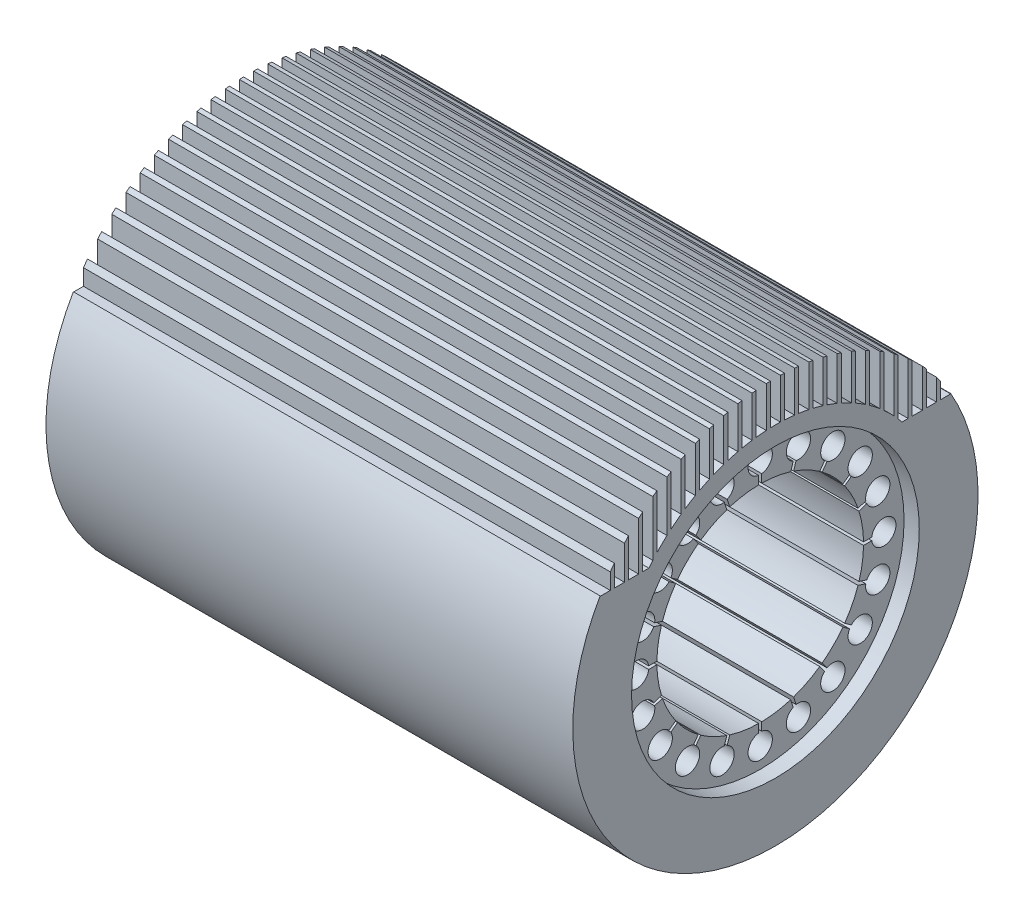
from build123d import *

# Parameters (mm, degrees)
CUT_EXTRUDE1_REACH = 262
CUT_EXTRUDE3_DEPTH = 260


with BuildPart() as part:
    # Sketch1 → Revolve1 (revolve)
    with BuildSketch(Plane.XY):
        Polygon((-130, 100), (130, 100), (130, 71), (122.5, 71), (122.5, 51), (-122.5, 51), (-122.5, 71), (-130, 71), align=None)
    revolve(axis=Axis((-130, 0, 0), (1, 0, 0)))

    # Sketch2 → Cut-Extrude1 (cut, up to next)
    with BuildSketch(Plane.ZY.offset(130), mode=Mode.PRIVATE) as cut_extrude1_sk1:
        with BuildLine():
            Line((-0.75, 55.04705955), (-0.75, 50.994484996))
            ThreePointArc((-0.75, 50.994484996), (0, 51), (0.75, 50.994484996))
            Line((0.75, 50.994484996), (0.75, 55.04705955))
            ThreePointArc((0.75, 55.04705955), (0, 67), (-0.75, 55.04705955))
        make_face()
    cut_extrude1_tool1 = extrude(cut_extrude1_sk1.sketch, amount=-CUT_EXTRUDE1_REACH, mode=Mode.PRIVATE) & part.part
    add(cut_extrude1_tool1.solids().sort_by_distance((-130, 60.595645, 0))[0], mode=Mode.SUBTRACT)
    # Sketch2 → Cut-Extrude1 (cut, up to next)
    with BuildSketch(Plane.ZY.offset(130), mode=Mode.PRIVATE) as cut_extrude1_sk2:
        with BuildLine():
            Line((16.297184504, 52.584627434), (15.044870096, 48.730399996))
            ThreePointArc((15.044870096, 48.730399996), (15.759866713, 48.503882331), (16.47145487, 48.266874505))
            Line((16.47145487, 48.266874505), (17.723769279, 52.121101942))
            ThreePointArc((17.723769279, 52.121101942), (20.704138623, 63.720786592), (16.297184504, 52.584627434))
        make_face()
    cut_extrude1_tool2 = extrude(cut_extrude1_sk2.sketch, amount=-CUT_EXTRUDE1_REACH, mode=Mode.PRIVATE) & part.part
    add(cut_extrude1_tool2.solids().sort_by_distance((-130, 57.629883, 18.725084))[0], mode=Mode.SUBTRACT)
    # Sketch2 → Cut-Extrude1 (cut, up to next)
    with BuildSketch(Plane.ZY.offset(130), mode=Mode.PRIVATE) as cut_extrude1_sk3:
        with BuildLine():
            Line((31.74908704, 44.974845606), (29.367043483, 41.69624392))
            ThreePointArc((29.367043483, 41.69624392), (29.977047867, 41.259866713), (30.580568975, 40.814566042))
            Line((30.580568975, 40.814566042), (32.962612531, 44.093167727))
            ThreePointArc((32.962612531, 44.093167727), (39.381611904, 54.204138623), (31.74908704, 44.974845606))
        make_face()
    cut_extrude1_tool3 = extrude(cut_extrude1_sk3.sketch, amount=-CUT_EXTRUDE1_REACH, mode=Mode.PRIVATE) & part.part
    add(cut_extrude1_tool3.solids().sort_by_distance((-130, 49.022907, 35.617227))[0], mode=Mode.SUBTRACT)
    # Sketch2 → Cut-Extrude1 (cut, up to next)
    with BuildSketch(Plane.ZY.offset(130), mode=Mode.PRIVATE) as cut_extrude1_sk4:
        with BuildLine():
            Line((44.093167727, 32.962612531), (40.814566042, 30.580568975))
            ThreePointArc((40.814566042, 30.580568975), (41.259866713, 29.977047867), (41.69624392, 29.367043483))
            Line((41.69624392, 29.367043483), (44.974845606, 31.74908704))
            ThreePointArc((44.974845606, 31.74908704), (54.204138623, 39.381611904), (44.093167727, 32.962612531))
        make_face()
    cut_extrude1_tool4 = extrude(cut_extrude1_sk4.sketch, amount=-CUT_EXTRUDE1_REACH, mode=Mode.PRIVATE) & part.part
    add(cut_extrude1_tool4.solids().sort_by_distance((-130, 35.617227, 49.022907))[0], mode=Mode.SUBTRACT)
    # Sketch2 → Cut-Extrude1 (cut, up to next)
    with BuildSketch(Plane.ZY.offset(130), mode=Mode.PRIVATE) as cut_extrude1_sk5:
        with BuildLine():
            Line((52.121101942, 17.723769279), (48.266874505, 16.47145487))
            ThreePointArc((48.266874505, 16.47145487), (48.503882331, 15.759866713), (48.730399996, 15.044870096))
            Line((48.730399996, 15.044870096), (52.584627434, 16.297184504))
            ThreePointArc((52.584627434, 16.297184504), (63.720786592, 20.704138623), (52.121101942, 17.723769279))
        make_face()
    cut_extrude1_tool5 = extrude(cut_extrude1_sk5.sketch, amount=-CUT_EXTRUDE1_REACH, mode=Mode.PRIVATE) & part.part
    add(cut_extrude1_tool5.solids().sort_by_distance((-130, 18.725084, 57.629883))[0], mode=Mode.SUBTRACT)
    # Sketch2 → Cut-Extrude1 (cut, up to next)
    with BuildSketch(Plane.ZY.offset(130), mode=Mode.PRIVATE) as cut_extrude1_sk6:
        with BuildLine():
            Line((55.04705955, 0.75), (50.994484996, 0.75))
            ThreePointArc((50.994484996, 0.75), (51, 0), (50.994484996, -0.75))
            Line((50.994484996, -0.75), (55.04705955, -0.75))
            ThreePointArc((55.04705955, -0.75), (67, 0), (55.04705955, 0.75))
        make_face()
    cut_extrude1_tool6 = extrude(cut_extrude1_sk6.sketch, amount=-CUT_EXTRUDE1_REACH, mode=Mode.PRIVATE) & part.part
    add(cut_extrude1_tool6.solids().sort_by_distance((-130, 0, 60.595645))[0], mode=Mode.SUBTRACT)
    # Sketch2 → Cut-Extrude1 (cut, up to next)
    with BuildSketch(Plane.ZY.offset(130), mode=Mode.PRIVATE) as cut_extrude1_sk7:
        with BuildLine():
            Line((52.584627434, -16.297184504), (48.730399996, -15.044870096))
            ThreePointArc((48.730399996, -15.044870096), (48.503882331, -15.759866713), (48.266874505, -16.47145487))
            Line((48.266874505, -16.47145487), (52.121101942, -17.723769279))
            ThreePointArc((52.121101942, -17.723769279), (63.720786592, -20.704138623), (52.584627434, -16.297184504))
        make_face()
    cut_extrude1_tool7 = extrude(cut_extrude1_sk7.sketch, amount=-CUT_EXTRUDE1_REACH, mode=Mode.PRIVATE) & part.part
    add(cut_extrude1_tool7.solids().sort_by_distance((-130, -18.725084, 57.629883))[0], mode=Mode.SUBTRACT)
    # Sketch2 → Cut-Extrude1 (cut, up to next)
    with BuildSketch(Plane.ZY.offset(130), mode=Mode.PRIVATE) as cut_extrude1_sk8:
        with BuildLine():
            Line((44.974845606, -31.74908704), (41.69624392, -29.367043483))
            ThreePointArc((41.69624392, -29.367043483), (41.259866713, -29.977047867), (40.814566042, -30.580568975))
            Line((40.814566042, -30.580568975), (44.093167727, -32.962612531))
            ThreePointArc((44.093167727, -32.962612531), (54.204138623, -39.381611904), (44.974845606, -31.74908704))
        make_face()
    cut_extrude1_tool8 = extrude(cut_extrude1_sk8.sketch, amount=-CUT_EXTRUDE1_REACH, mode=Mode.PRIVATE) & part.part
    add(cut_extrude1_tool8.solids().sort_by_distance((-130, -35.617227, 49.022907))[0], mode=Mode.SUBTRACT)
    # Sketch2 → Cut-Extrude1 (cut, up to next)
    with BuildSketch(Plane.ZY.offset(130), mode=Mode.PRIVATE) as cut_extrude1_sk9:
        with BuildLine():
            Line((32.962612531, -44.093167727), (30.580568975, -40.814566042))
            ThreePointArc((30.580568975, -40.814566042), (29.977047867, -41.259866713), (29.367043483, -41.69624392))
            Line((29.367043483, -41.69624392), (31.74908704, -44.974845606))
            ThreePointArc((31.74908704, -44.974845606), (39.381611904, -54.204138623), (32.962612531, -44.093167727))
        make_face()
    cut_extrude1_tool9 = extrude(cut_extrude1_sk9.sketch, amount=-CUT_EXTRUDE1_REACH, mode=Mode.PRIVATE) & part.part
    add(cut_extrude1_tool9.solids().sort_by_distance((-130, -49.022907, 35.617227))[0], mode=Mode.SUBTRACT)
    # Sketch2 → Cut-Extrude1 (cut, up to next)
    with BuildSketch(Plane.ZY.offset(130), mode=Mode.PRIVATE) as cut_extrude1_sk10:
        with BuildLine():
            Line((17.723769279, -52.121101942), (16.47145487, -48.266874505))
            ThreePointArc((16.47145487, -48.266874505), (15.759866713, -48.503882331), (15.044870096, -48.730399996))
            Line((15.044870096, -48.730399996), (16.297184504, -52.584627434))
            ThreePointArc((16.297184504, -52.584627434), (20.704138623, -63.720786592), (17.723769279, -52.121101942))
        make_face()
    cut_extrude1_tool10 = extrude(cut_extrude1_sk10.sketch, amount=-CUT_EXTRUDE1_REACH, mode=Mode.PRIVATE) & part.part
    add(cut_extrude1_tool10.solids().sort_by_distance((-130, -57.629883, 18.725084))[0], mode=Mode.SUBTRACT)
    # Sketch2 → Cut-Extrude1 (cut, up to next)
    with BuildSketch(Plane.ZY.offset(130), mode=Mode.PRIVATE) as cut_extrude1_sk11:
        with BuildLine():
            Line((0.75, -55.04705955), (0.75, -50.994484996))
            ThreePointArc((0.75, -50.994484996), (0, -51), (-0.75, -50.994484996))
            Line((-0.75, -50.994484996), (-0.75, -55.04705955))
            ThreePointArc((-0.75, -55.04705955), (0, -67), (0.75, -55.04705955))
        make_face()
    cut_extrude1_tool11 = extrude(cut_extrude1_sk11.sketch, amount=-CUT_EXTRUDE1_REACH, mode=Mode.PRIVATE) & part.part
    add(cut_extrude1_tool11.solids().sort_by_distance((-130, -60.595645, 0))[0], mode=Mode.SUBTRACT)
    # Sketch2 → Cut-Extrude1 (cut, up to next)
    with BuildSketch(Plane.ZY.offset(130), mode=Mode.PRIVATE) as cut_extrude1_sk12:
        with BuildLine():
            Line((-16.297184504, -52.584627434), (-15.044870096, -48.730399996))
            ThreePointArc((-15.044870096, -48.730399996), (-15.759866713, -48.503882331), (-16.47145487, -48.266874505))
            Line((-16.47145487, -48.266874505), (-17.723769279, -52.121101942))
            ThreePointArc((-17.723769279, -52.121101942), (-20.704138623, -63.720786592), (-16.297184504, -52.584627434))
        make_face()
    cut_extrude1_tool12 = extrude(cut_extrude1_sk12.sketch, amount=-CUT_EXTRUDE1_REACH, mode=Mode.PRIVATE) & part.part
    add(cut_extrude1_tool12.solids().sort_by_distance((-130, -57.629883, -18.725084))[0], mode=Mode.SUBTRACT)
    # Sketch2 → Cut-Extrude1 (cut, up to next)
    with BuildSketch(Plane.ZY.offset(130), mode=Mode.PRIVATE) as cut_extrude1_sk13:
        with BuildLine():
            Line((-31.74908704, -44.974845606), (-29.367043483, -41.69624392))
            ThreePointArc((-29.367043483, -41.69624392), (-29.977047867, -41.259866713), (-30.580568975, -40.814566042))
            Line((-30.580568975, -40.814566042), (-32.962612531, -44.093167727))
            ThreePointArc((-32.962612531, -44.093167727), (-39.381611904, -54.204138623), (-31.74908704, -44.974845606))
        make_face()
    cut_extrude1_tool13 = extrude(cut_extrude1_sk13.sketch, amount=-CUT_EXTRUDE1_REACH, mode=Mode.PRIVATE) & part.part
    add(cut_extrude1_tool13.solids().sort_by_distance((-130, -49.022907, -35.617227))[0], mode=Mode.SUBTRACT)
    # Sketch2 → Cut-Extrude1 (cut, up to next)
    with BuildSketch(Plane.ZY.offset(130), mode=Mode.PRIVATE) as cut_extrude1_sk14:
        with BuildLine():
            Line((-44.093167727, -32.962612531), (-40.814566042, -30.580568975))
            ThreePointArc((-40.814566042, -30.580568975), (-41.259866713, -29.977047867), (-41.69624392, -29.367043483))
            Line((-41.69624392, -29.367043483), (-44.974845606, -31.74908704))
            ThreePointArc((-44.974845606, -31.74908704), (-54.204138623, -39.381611904), (-44.093167727, -32.962612531))
        make_face()
    cut_extrude1_tool14 = extrude(cut_extrude1_sk14.sketch, amount=-CUT_EXTRUDE1_REACH, mode=Mode.PRIVATE) & part.part
    add(cut_extrude1_tool14.solids().sort_by_distance((-130, -35.617227, -49.022907))[0], mode=Mode.SUBTRACT)
    # Sketch2 → Cut-Extrude1 (cut, up to next)
    with BuildSketch(Plane.ZY.offset(130), mode=Mode.PRIVATE) as cut_extrude1_sk15:
        with BuildLine():
            Line((-52.121101942, -17.723769279), (-48.266874505, -16.47145487))
            ThreePointArc((-48.266874505, -16.47145487), (-48.503882331, -15.759866713), (-48.730399996, -15.044870096))
            Line((-48.730399996, -15.044870096), (-52.584627434, -16.297184504))
            ThreePointArc((-52.584627434, -16.297184504), (-63.720786592, -20.704138623), (-52.121101942, -17.723769279))
        make_face()
    cut_extrude1_tool15 = extrude(cut_extrude1_sk15.sketch, amount=-CUT_EXTRUDE1_REACH, mode=Mode.PRIVATE) & part.part
    add(cut_extrude1_tool15.solids().sort_by_distance((-130, -18.725084, -57.629883))[0], mode=Mode.SUBTRACT)
    # Sketch2 → Cut-Extrude1 (cut, up to next)
    with BuildSketch(Plane.ZY.offset(130), mode=Mode.PRIVATE) as cut_extrude1_sk16:
        with BuildLine():
            Line((-55.04705955, -0.75), (-50.994484996, -0.75))
            ThreePointArc((-50.994484996, -0.75), (-51, 0), (-50.994484996, 0.75))
            Line((-50.994484996, 0.75), (-55.04705955, 0.75))
            ThreePointArc((-55.04705955, 0.75), (-67, 0), (-55.04705955, -0.75))
        make_face()
    cut_extrude1_tool16 = extrude(cut_extrude1_sk16.sketch, amount=-CUT_EXTRUDE1_REACH, mode=Mode.PRIVATE) & part.part
    add(cut_extrude1_tool16.solids().sort_by_distance((-130, 0, -60.595645))[0], mode=Mode.SUBTRACT)
    # Sketch2 → Cut-Extrude1 (cut, up to next)
    with BuildSketch(Plane.ZY.offset(130), mode=Mode.PRIVATE) as cut_extrude1_sk17:
        with BuildLine():
            Line((-52.584627434, 16.297184504), (-48.730399996, 15.044870096))
            ThreePointArc((-48.730399996, 15.044870096), (-48.503882331, 15.759866713), (-48.266874505, 16.47145487))
            Line((-48.266874505, 16.47145487), (-52.121101942, 17.723769279))
            ThreePointArc((-52.121101942, 17.723769279), (-63.720786592, 20.704138623), (-52.584627434, 16.297184504))
        make_face()
    cut_extrude1_tool17 = extrude(cut_extrude1_sk17.sketch, amount=-CUT_EXTRUDE1_REACH, mode=Mode.PRIVATE) & part.part
    add(cut_extrude1_tool17.solids().sort_by_distance((-130, 18.725084, -57.629883))[0], mode=Mode.SUBTRACT)
    # Sketch2 → Cut-Extrude1 (cut, up to next)
    with BuildSketch(Plane.ZY.offset(130), mode=Mode.PRIVATE) as cut_extrude1_sk18:
        with BuildLine():
            Line((-44.974845606, 31.74908704), (-41.69624392, 29.367043483))
            ThreePointArc((-41.69624392, 29.367043483), (-41.259866713, 29.977047867), (-40.814566042, 30.580568975))
            Line((-40.814566042, 30.580568975), (-44.093167727, 32.962612531))
            ThreePointArc((-44.093167727, 32.962612531), (-54.204138623, 39.381611904), (-44.974845606, 31.74908704))
        make_face()
    cut_extrude1_tool18 = extrude(cut_extrude1_sk18.sketch, amount=-CUT_EXTRUDE1_REACH, mode=Mode.PRIVATE) & part.part
    add(cut_extrude1_tool18.solids().sort_by_distance((-130, 35.617227, -49.022907))[0], mode=Mode.SUBTRACT)
    # Sketch2 → Cut-Extrude1 (cut, up to next)
    with BuildSketch(Plane.ZY.offset(130), mode=Mode.PRIVATE) as cut_extrude1_sk19:
        with BuildLine():
            Line((-32.962612531, 44.093167727), (-30.580568975, 40.814566042))
            ThreePointArc((-30.580568975, 40.814566042), (-29.977047867, 41.259866713), (-29.367043483, 41.69624392))
            Line((-29.367043483, 41.69624392), (-31.74908704, 44.974845606))
            ThreePointArc((-31.74908704, 44.974845606), (-39.381611904, 54.204138623), (-32.962612531, 44.093167727))
        make_face()
    cut_extrude1_tool19 = extrude(cut_extrude1_sk19.sketch, amount=-CUT_EXTRUDE1_REACH, mode=Mode.PRIVATE) & part.part
    add(cut_extrude1_tool19.solids().sort_by_distance((-130, 49.022907, -35.617227))[0], mode=Mode.SUBTRACT)
    # Sketch2 → Cut-Extrude1 (cut, up to next)
    with BuildSketch(Plane.ZY.offset(130), mode=Mode.PRIVATE) as cut_extrude1_sk20:
        with BuildLine():
            Line((-17.723769279, 52.121101942), (-16.47145487, 48.266874505))
            ThreePointArc((-16.47145487, 48.266874505), (-15.759866713, 48.503882331), (-15.044870096, 48.730399996))
            Line((-15.044870096, 48.730399996), (-16.297184504, 52.584627434))
            ThreePointArc((-16.297184504, 52.584627434), (-20.704138623, 63.720786592), (-17.723769279, 52.121101942))
        make_face()
    cut_extrude1_tool20 = extrude(cut_extrude1_sk20.sketch, amount=-CUT_EXTRUDE1_REACH, mode=Mode.PRIVATE) & part.part
    add(cut_extrude1_tool20.solids().sort_by_distance((-130, 57.629883, -18.725084))[0], mode=Mode.SUBTRACT)

    # Sketch4 → Cut-Extrude3 (cut)
    with BuildSketch(Plane.ZY.offset(130)):
        with BuildLine():
            ThreePointArc((4.5, 79.873337228), (7.00344691, 79.692858723), (9.5, 79.433934814))
            Line((9.5, 79.433934814), (9.5, 99.547727247))
            ThreePointArc((9.5, 99.547727247), (7.002199314, 99.754544782), (4.5, 99.89869869))
            Line((4.5, 99.89869869), (4.5, 79.873337228))
        make_face()
        with BuildLine():
            Line((11.5, 99.336549165), (11.5, 79.169122769))
            ThreePointArc((11.5, 79.169122769), (14.00705746, 78.764219931), (16.5, 78.279946346))
            Line((16.5, 78.279946346), (16.5, 98.629356685))
            ThreePointArc((16.5, 98.629356685), (14.004464656, 99.014518984), (11.5, 99.336549165))
        make_face()
        with BuildLine():
            ThreePointArc((-2.5, 79.960927959), (0, 80), (2.5, 79.960927959))
            Line((2.5, 79.960927959), (2.5, 99.968745116))
            ThreePointArc((2.5, 99.968745116), (0, 100), (-2.5, 99.968745116))
            Line((-2.5, 99.968745116), (-2.5, 79.960927959))
        make_face()
        with BuildLine():
            Line((18.5, 98.273852067), (18.5, 77.831548873))
            ThreePointArc((18.5, 77.831548873), (21.011022281, 77.191560048), (23.5, 76.470582579))
            Line((23.5, 76.470582579), (23.5, 97.199537036))
            ThreePointArc((23.5, 97.199537036), (21.006868834, 97.768662985), (18.5, 98.273852067))
        make_face()
        with BuildLine():
            ThreePointArc((-9.5, 79.433934814), (-7.00344691, 79.692858723), (-4.5, 79.873337228))
            Line((-4.5, 79.873337228), (-4.5, 99.89869869))
            ThreePointArc((-4.5, 99.89869869), (-7.002199314, 99.754544782), (-9.5, 99.547727247))
            Line((-9.5, 99.547727247), (-9.5, 79.433934814))
        make_face()
        with BuildLine():
            Line((25.5, 96.694105301), (25.5, 75.827105971))
            ThreePointArc((25.5, 75.827105971), (28.015595929, 74.934146987), (30.5, 73.957758214))
            Line((30.5, 73.957758214), (30.5, 95.235235076))
            ThreePointArc((30.5, 95.235235076), (28.009499738, 95.997228733), (25.5, 96.694105301))
        make_face()
        with BuildLine():
            ThreePointArc((-16.5, 78.279946346), (-14.00705746, 78.764219931), (-11.5, 79.169122769))
            Line((-11.5, 79.169122769), (-11.5, 99.336549165))
            ThreePointArc((-11.5, 99.336549165), (-14.004464656, 99.014518984), (-16.5, 98.629356685))
            Line((-16.5, 98.629356685), (-16.5, 78.279946346))
        make_face()
        with BuildLine():
            Line((32.5, 94.571401597), (32.5, 73.100957586))
            ThreePointArc((32.5, 73.100957586), (35.021160493, 71.927173709), (37.5, 70.666470126))
            Line((37.5, 70.666470126), (37.5, 92.702481089))
            ThreePointArc((37.5, 92.702481089), (35.012472292, 93.670308978), (32.5, 94.571401597))
        make_face()
        with BuildLine():
            ThreePointArc((-23.5, 76.470582579), (-21.011022281, 77.191560048), (-18.5, 77.831548873))
            Line((-18.5, 77.831548873), (-18.5, 98.273852067))
            ThreePointArc((-18.5, 98.273852067), (-21.006868834, 97.768662985), (-23.5, 97.199537036))
            Line((-23.5, 97.199537036), (-23.5, 76.470582579))
        make_face()
        with BuildLine():
            Line((39.5, 91.868111987), (39.5, 69.568311752))
            ThreePointArc((39.5, 69.568311752), (42.028354289, 68.070679707), (44.5, 66.48120035))
            Line((44.5, 66.48120035), (44.5, 89.553056899))
            ThreePointArc((44.5, 89.553056899), (42.015947806, 90.745028128), (39.5, 91.868111987))
        make_face()
        with BuildLine():
            ThreePointArc((-30.5, 73.957758214), (-28.015595929, 74.934146987), (-25.5, 75.827105971))
            Line((-25.5, 75.827105971), (-25.5, 96.694105301))
            ThreePointArc((-25.5, 96.694105301), (-28.009499738, 95.997228733), (-30.5, 95.235235076))
            Line((-30.5, 95.235235076), (-30.5, 73.957758214))
        make_face()
        with BuildLine():
            Line((46.5, 88.531067993), (46.5, 65.098003042))
            ThreePointArc((46.5, 65.098003042), (49.038371904, 63.207895717), (51.5, 61.21886964))
            Line((51.5, 61.21886964), (51.5, 85.719017727))
            ThreePointArc((51.5, 85.719017727), (49.020168366, 87.160903468), (46.5, 88.531067993))
        make_face()
        with BuildLine():
            ThreePointArc((-37.5, 70.666470126), (-35.021160493, 71.927173709), (-32.5, 73.100957586))
            Line((-32.5, 73.100957586), (-32.5, 94.571401597))
            ThreePointArc((-32.5, 94.571401597), (-35.012472292, 93.670308978), (-37.5, 92.702481089))
            Line((-37.5, 92.702481089), (-37.5, 70.666470126))
        make_face()
        with BuildLine():
            Line((53.5, 84.485205806), (53.5, 59.478987886))
            ThreePointArc((53.5, 59.478987886), (56.053791796, 57.078651221), (58.5, 54.568763959))
            Line((58.5, 54.568763959), (58.5, 81.103329155))
            ThreePointArc((58.5, 81.103329155), (56.025523402, 82.83200304), (53.5, 84.485205806))
        make_face()
        with BuildLine():
            ThreePointArc((-44.5, 66.48120035), (-42.028354289, 68.070679707), (-39.5, 69.568311752))
            Line((-39.5, 69.568311752), (-39.5, 91.868111987))
            ThreePointArc((-39.5, 91.868111987), (-42.015947806, 90.745028128), (-44.5, 89.553056899))
            Line((-44.5, 89.553056899), (-44.5, 66.48120035))
        make_face()
        with BuildLine():
            Line((60.5, 79.622547058), (60.5, 52.342621256))
            ThreePointArc((60.5, 52.342621256), (61.486147733, 51.180598247), (62.449979984, 50))
            Line((62.449979984, 50), (65.5, 50))
            Line((65.5, 50), (65.5, 75.562887716))
            ThreePointArc((65.5, 75.562887716), (63.032691585, 77.632981339), (60.5, 79.622547058))
        make_face()
        with BuildLine():
            ThreePointArc((-51.5, 61.21886964), (-49.038371904, 63.207895717), (-46.5, 65.098003042))
            Line((-46.5, 65.098003042), (-46.5, 88.531067993))
            ThreePointArc((-46.5, 88.531067993), (-49.020168366, 87.160903468), (-51.5, 85.719017727))
            Line((-51.5, 85.719017727), (-51.5, 61.21886964))
        make_face()
        with BuildLine():
            ThreePointArc((72.5, 68.87488657), (70.042982398, 71.372127731), (67.5, 73.781772817))
            Line((67.5, 73.781772817), (67.5, 50))
            Line((67.5, 50), (72.5, 50))
            Line((72.5, 50), (72.5, 68.87488657))
        make_face()
        with BuildLine():
            Line((-65.5, 50), (-62.449979984, 50))
            ThreePointArc((-62.449979984, 50), (-61.486147733, 51.180598247), (-60.5, 52.342621256))
            Line((-60.5, 52.342621256), (-60.5, 79.622547058))
            ThreePointArc((-60.5, 79.622547058), (-63.032691585, 77.632981339), (-65.5, 75.562887716))
            Line((-65.5, 75.562887716), (-65.5, 50))
        make_face()
        with BuildLine():
            ThreePointArc((-58.5, 54.568763959), (-56.053791796, 57.078651221), (-53.5, 59.478987886))
            Line((-53.5, 59.478987886), (-53.5, 84.485205806))
            ThreePointArc((-53.5, 84.485205806), (-56.025523402, 82.83200304), (-58.5, 81.103329155))
            Line((-58.5, 81.103329155), (-58.5, 54.568763959))
        make_face()
        with BuildLine():
            ThreePointArc((79.5, 60.660942953), (77.059308511, 63.732746464), (74.5, 66.706446465))
            Line((74.5, 66.706446465), (74.5, 50))
            Line((74.5, 50), (79.5, 50))
            Line((79.5, 50), (79.5, 60.660942953))
        make_face()
        with BuildLine():
            Line((-67.5, 50), (-67.5, 73.781772817))
            ThreePointArc((-67.5, 73.781772817), (-70.042982398, 71.372127731), (-72.5, 68.87488657))
            Line((-72.5, 68.87488657), (-72.5, 50))
            Line((-72.5, 50), (-67.5, 50))
        make_face()
        with BuildLine():
            ThreePointArc((86.5, 50.177186051), (84.089767446, 54.119414363), (81.5, 57.946095641))
            Line((81.5, 57.946095641), (81.5, 50))
            Line((81.5, 50), (86.5, 50))
            Line((86.5, 50), (86.5, 50.177186051))
        make_face()
        with BuildLine():
            Line((-74.5, 50), (-74.5, 66.706446465))
            ThreePointArc((-74.5, 66.706446465), (-77.059308511, 63.732746464), (-79.5, 60.660942953))
            Line((-79.5, 60.660942953), (-79.5, 50))
            Line((-79.5, 50), (-74.5, 50))
        make_face()
        with BuildLine():
            ThreePointArc((-81.5, 57.946095641), (-84.089767446, 54.119414363), (-86.5, 50.177186051))
            Line((-86.5, 50.177186051), (-86.5, 50))
            Line((-86.5, 50), (-81.5, 50))
            Line((-81.5, 50), (-81.5, 57.946095641))
        make_face()
    extrude(amount=-CUT_EXTRUDE3_DEPTH, mode=Mode.SUBTRACT)


solid = part.part
